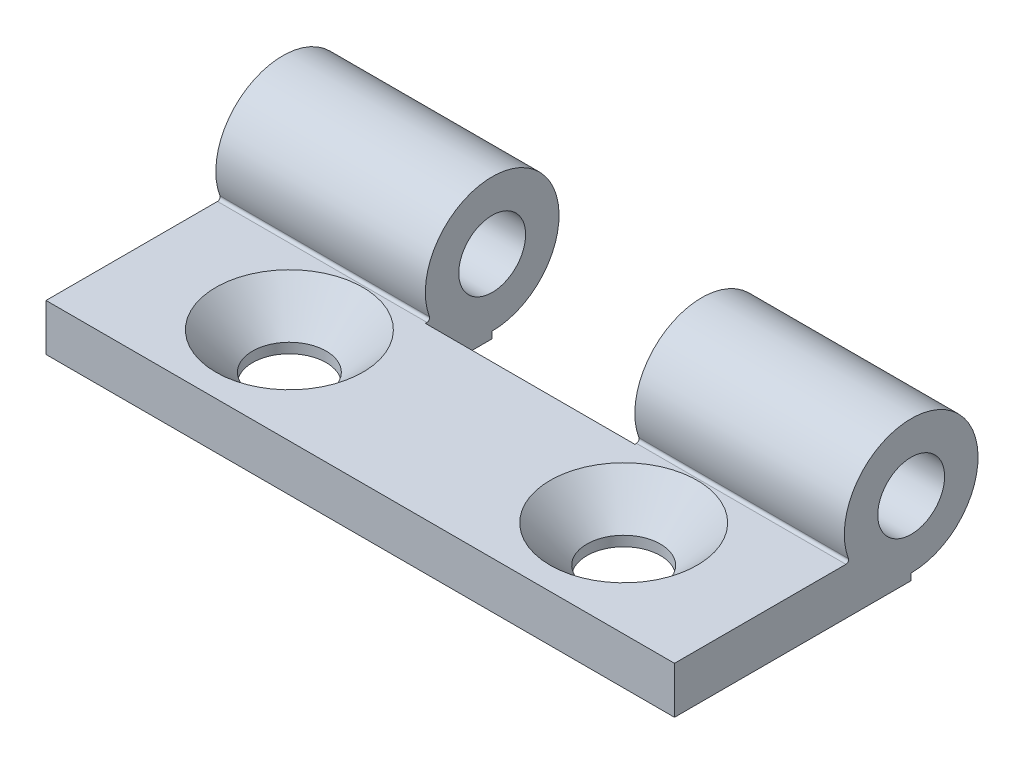
from build123d import *

# Parameters (mm, degrees)
SKETCH1_R                = 2.5
BOSS_EXTRUDE1_DEPTH      = 36
BOSS_EXTRUDE1_DEPTH_BACK = 11
FILLET1_R                = 0.2
SKETCH2_W                = 15.666666666
SKETCH2_H                = 10
SKETCH2_W_2              = 15.666666667
CUT_EXTRUDE1_DEPTH       = 11.5
CSK1_AT_2_COUNT          = 2
CSK1_AT_2_PITCH          = 25


with BuildPart() as part:
    # Sketch1 → Boss-Extrude1 (new body, two sides)
    with BuildSketch(Plane(origin=(0, 0, 0), x_dir=(0, 0, -1), z_dir=(1, 0, 0))) as boss_extrude1_sk:
        with BuildLine():
            Line((-28.2, 0), (-10.5, 0))
            Line((-10.5, 0), (-10.5, 0.5))
            ThreePointArc((-10.5, 0.5), (-7.761387212, 9.683300133), (-15.082575695, 3.5))
            Line((-15.082575695, 3.5), (-28.2, 3.5))
            Line((-28.2, 3.5), (-28.2, 0))
        make_face()
        with Locations((-10.5, 5.5)):
            Circle(SKETCH1_R, mode=Mode.SUBTRACT)
    extrude(amount=BOSS_EXTRUDE1_DEPTH)
    extrude(boss_extrude1_sk.sketch, amount=-BOSS_EXTRUDE1_DEPTH_BACK)

    # Fillet1
    fillet1_edges = [part.edges().sort_by_distance(p)[0] for p in [
        (12.5, 3.5, 15.082575695),
    ]]
    fillet(fillet1_edges, radius=FILLET1_R)

    # Sketch2 → Cut-Extrude1 (cut, through all)
    with BuildSketch(Plane(origin=(0, 0, 0), x_dir=(1, 0, 0), z_dir=(0, 1, 0))):
        with Locations((12.5, -10.5)):
            Rectangle(SKETCH2_W, SKETCH2_H)
        with Locations((43.833333334, -10.5)):
            Rectangle(SKETCH2_W_2, SKETCH2_H)
    extrude(amount=CUT_EXTRUDE1_DEPTH, mode=Mode.SUBTRACT)

    # Sketch3 → CSK1 (revolve, cut)
    with BuildSketch(Plane(origin=(0, 3.5, 21), x_dir=(0, 0, 1), z_dir=(1, 0, 0))):
        Polygon((0, 0), (0, 3.50005), (2.75, 3.50005), (2.75, 2.75), (5.5, 0), align=None)
    csk1 = revolve(axis=Axis((0, 9.85, 21), (0, -1, 0)), mode=Mode.SUBTRACT)

    # CSK1 at 2: CSK1 ×2
    with Locations(*[(i * CSK1_AT_2_PITCH, 0, 0) for i in range(1, CSK1_AT_2_COUNT)]):
        add(csk1, mode=Mode.SUBTRACT)


solid = part.part
